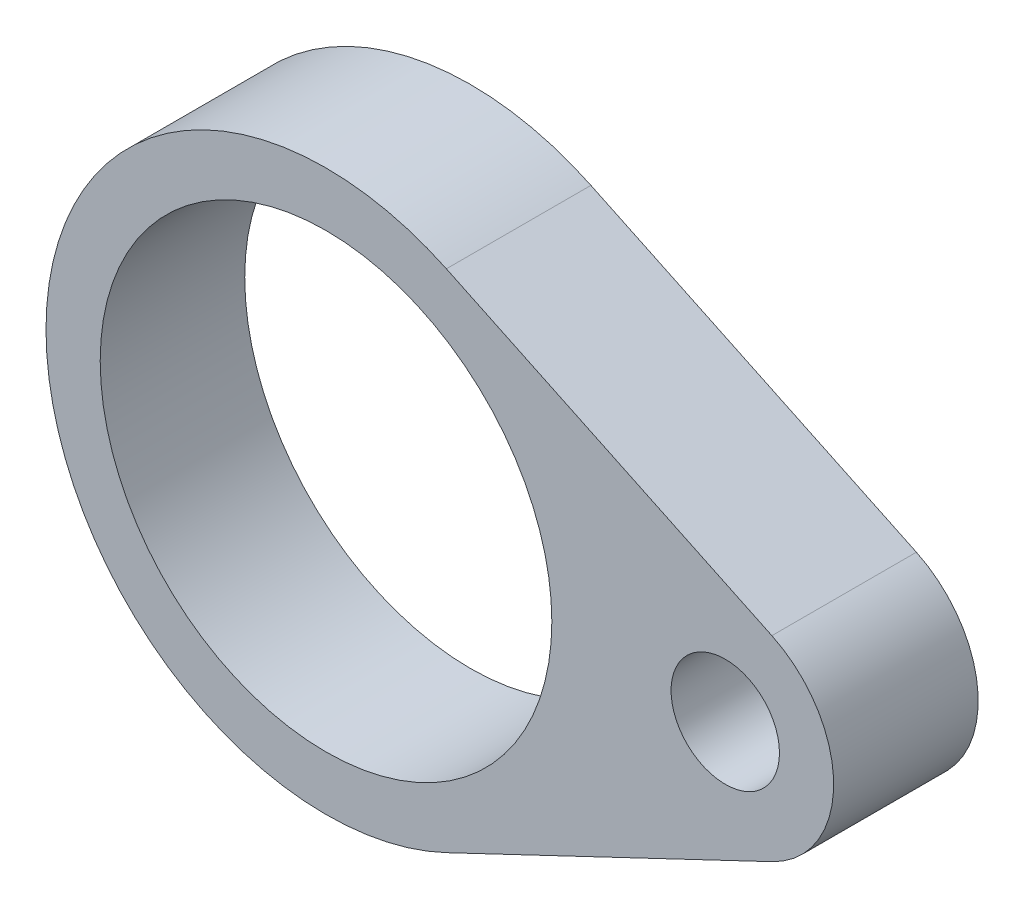
from build123d import *

# Parameters (mm, degrees)
SKETCH_1_R      = 12.5
SKETCH_1_R_2    = 3
EXTRUDE_1_DEPTH = 8


with BuildPart() as part:
    # 草图1 → 凸台-拉伸1 (new body)
    with BuildSketch(Plane.XY):
        with BuildLine():
            Line((6.662895928, 13.99484969), (24.67918552, 5.41736117))
            ThreePointArc((24.67918552, 5.41736117), (28.1, 0), (24.67918552, -5.41736117))
            Line((24.67918552, -5.41736117), (6.662895928, -13.99484969))
            ThreePointArc((6.662895928, -13.99484969), (-15.5, 0), (6.662895928, 13.99484969))
        make_face()
        Circle(SKETCH_1_R, mode=Mode.SUBTRACT)
        with Locations((22.1, 0)):
            Circle(SKETCH_1_R_2, mode=Mode.SUBTRACT)
    extrude(amount=EXTRUDE_1_DEPTH)


solid = part.part
